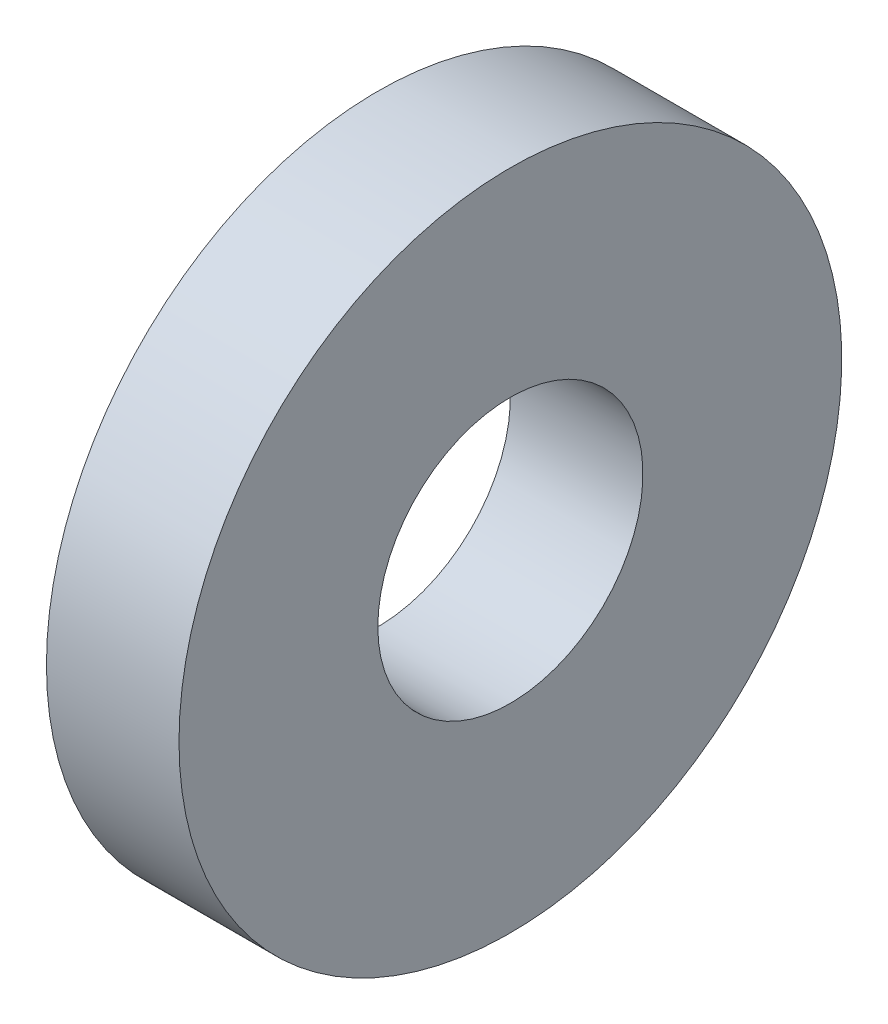
from build123d import *

# Parameters (mm, degrees)
SKETCH1_W = 5
SKETCH1_H = 7.5


with BuildPart() as part:
    # Sketch1 → Revolve4 (revolve)
    with BuildSketch(Plane.XY):
        with Locations((0, 8.75)):
            Rectangle(SKETCH1_W, SKETCH1_H)
    revolve(axis=Axis((0, 0, 0), (1, 0, 0)))


solid = part.part
